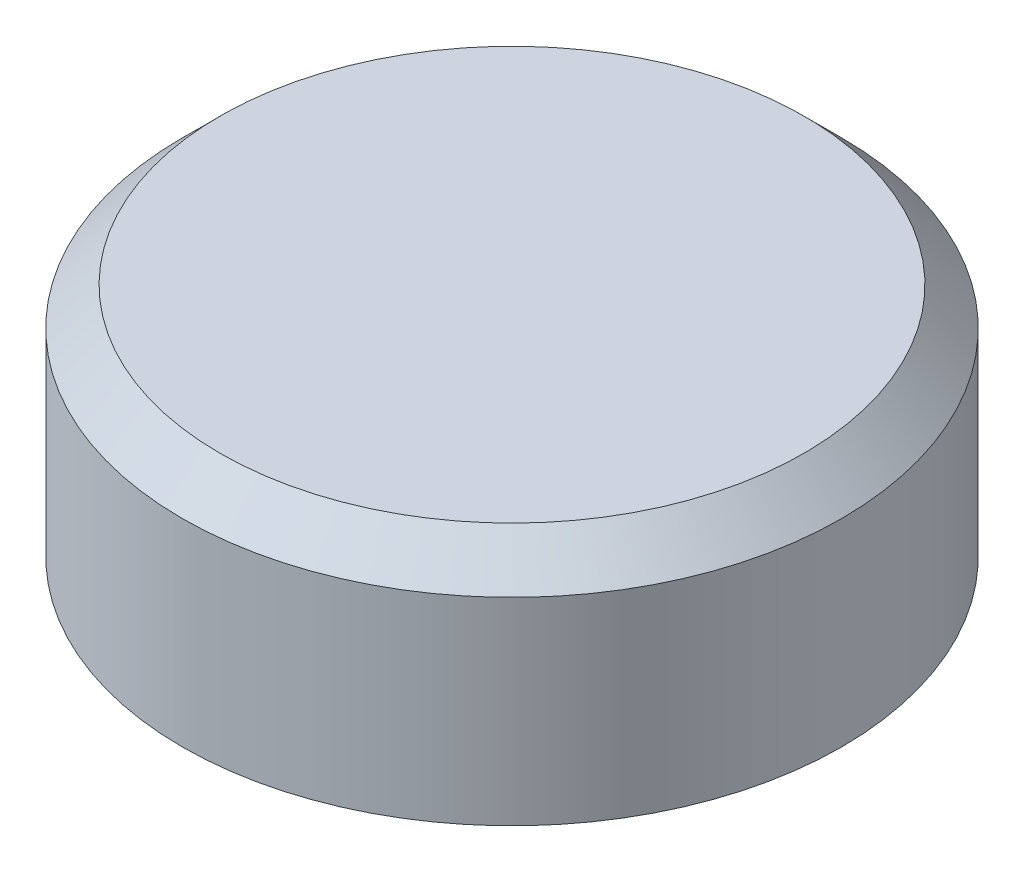
from build123d import *

# Parameters (mm, degrees)
SKETCH1_R           = 17.5
BOSS_EXTRUDE1_DEPTH = 12.5
SKETCH2_R           = 15.9
CUT_EXTRUDE1_DEPTH  = 11
CHAMFER1_SIZE       = 2
CHAMFER2_SIZE       = 2


with BuildPart() as part:
    # Sketch1 → Boss-Extrude1 (new body)
    with BuildSketch(Plane(origin=(0, 0, 0), x_dir=(1, 0, 0), z_dir=(0, 1, 0))):
        Circle(SKETCH1_R)
    extrude(amount=-BOSS_EXTRUDE1_DEPTH)

    # Sketch2 → Cut-Extrude1 (cut)
    with BuildSketch(Plane.XZ.offset(12.5)):
        Circle(SKETCH2_R)
    extrude(amount=-CUT_EXTRUDE1_DEPTH, mode=Mode.SUBTRACT)

    # Chamfer1
    chamfer1_edges = [part.edges().sort_by_distance(p)[0] for p in [
        (-17.5, 0, 0),
    ]]
    chamfer(chamfer1_edges, length=CHAMFER1_SIZE)

    # Chamfer2
    chamfer2_edges = [part.edges().sort_by_distance(p)[0] for p in [
        (-15.9, -1.5, 0),
    ]]
    chamfer(chamfer2_edges, length=CHAMFER2_SIZE)


solid = part.part
